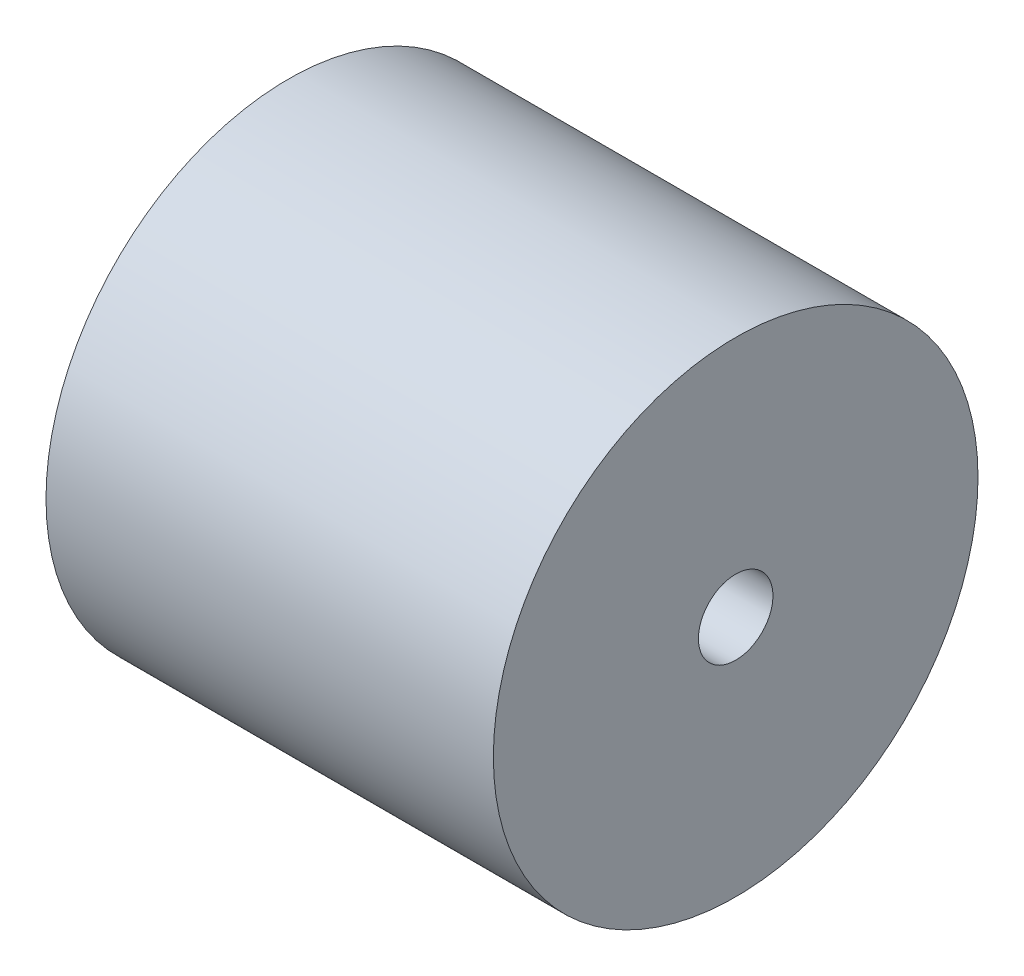
from build123d import *


with BuildPart() as part:
    # Sketch1 → Revolve2 (revolve)
    with BuildSketch(Plane.XY):
        with BuildLine():
            Line((-50.8, 69.85), (-50.8, 82.55))
            Line((-50.8, 82.55), (101.6, 82.55))
            Line((101.6, 82.55), (101.6, 12.7))
            Line((101.6, 12.7), (0, 12.7))
            Line((0, 12.7), (0, 25.4))
            ThreePointArc((0, 25.4), (-2.025659238, 31.58997261), (-7.62, 34.925))
            Line((-7.62, 34.925), (-24.13, 34.925))
            ThreePointArc((-24.13, 34.925), (-29.664711714, 38.307730629), (-31.75, 44.45))
            Line((-31.75, 44.45), (-31.75, 57.15))
            ThreePointArc((-31.75, 57.15), (-35.469743879, 66.130256121), (-44.45, 69.85))
            Line((-44.45, 69.85), (-50.8, 69.85))
        make_face()
    revolve(axis=Axis((0, 0, 0), (1, 0, 0)))


solid = part.part
